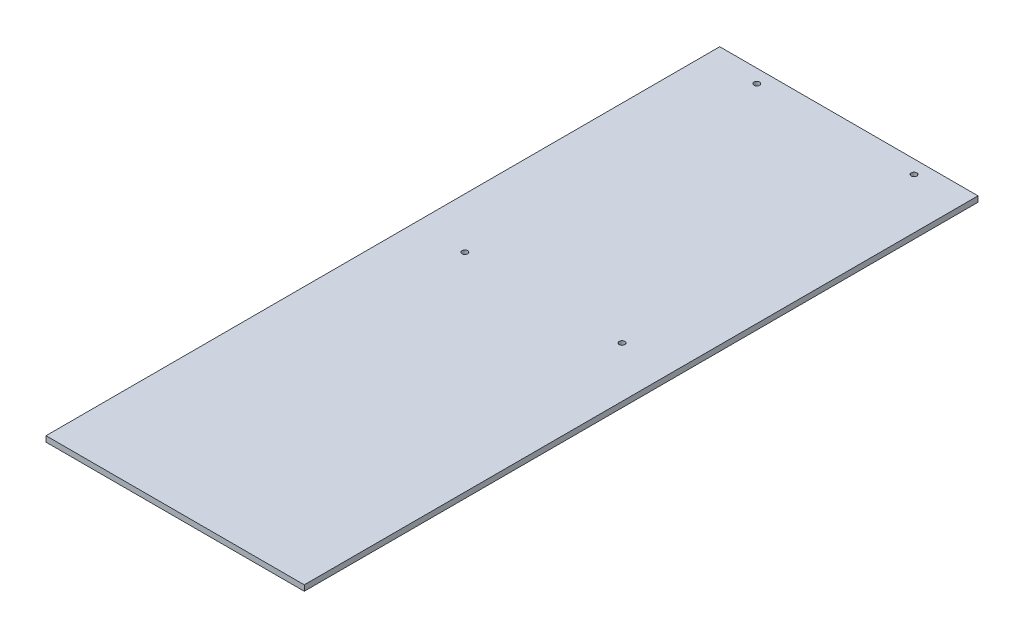
from build123d import *

# Parameters (mm, degrees)
SKETCH1_W           = 230
SKETCH1_H           = 600
BOSS_EXTRUDE1_DEPTH = 5
SKETCH2_R           = 2.5
CUT_EXTRUDE1_DEPTH  = 10


with BuildPart() as part:
    # Sketch1 → Boss-Extrude1 (new body)
    with BuildSketch(Plane(origin=(0, 0, 0), x_dir=(1, 0, 0), z_dir=(0, 1, 0))):
        with Locations((115, 300)):
            Rectangle(SKETCH1_W, SKETCH1_H)
    extrude(amount=BOSS_EXTRUDE1_DEPTH)

    # Sketch2 → Cut-Extrude1 (cut)
    with BuildSketch(Plane(origin=(0, 5, 0), x_dir=(1, 0, 0), z_dir=(0, 1, 0))):
        with Locations((185.01, 588)):
            Circle(SKETCH2_R)
        with Locations((44.99, 588)):
            Circle(SKETCH2_R)
        with Locations((185, 328.000000192)):
            Circle(SKETCH2_R)
        with Locations((45, 328.000000192)):
            Circle(SKETCH2_R)
    extrude(amount=-CUT_EXTRUDE1_DEPTH, mode=Mode.SUBTRACT)


solid = part.part
